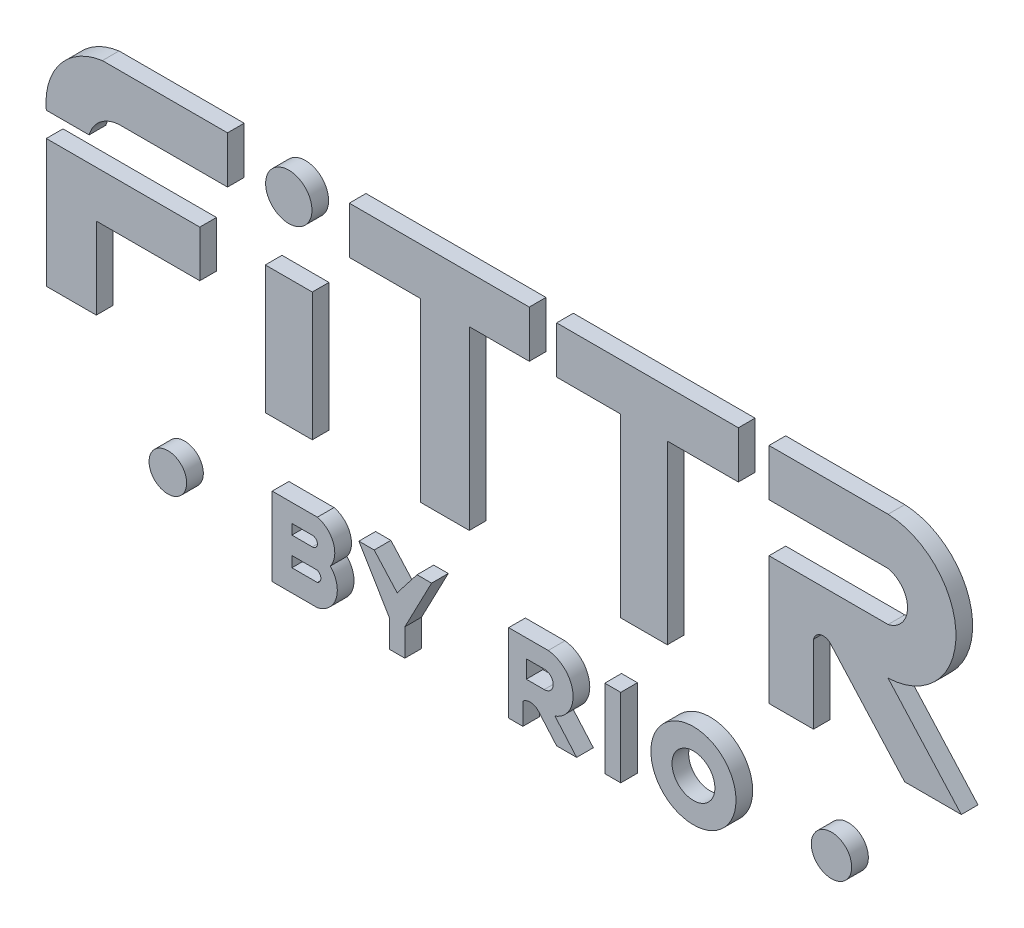
from build123d import *

# Parameters (mm, degrees)
SKETCH1_R              = 13.872950016
BOSS_EXTRUDE1_DEPTH    = 10
SKETCH1_R_2            = 11.261714239
BOSS_EXTRUDE1_2_DEPTH  = 10
SKETCH1_R_3            = 12.095962235
BOSS_EXTRUDE1_3_DEPTH  = 10
SKETCH1_R_4            = 25.497629654
SKETCH1_R_5            = 12.851526445
BOSS_EXTRUDE1_4_DEPTH  = 10
BOSS_EXTRUDE1_5_DEPTH  = 10
SKETCH1_W              = 28.160353525
SKETCH1_H              = 76.692026621
BOSS_EXTRUDE1_6_DEPTH  = 10
BOSS_EXTRUDE1_7_DEPTH  = 10
BOSS_EXTRUDE1_8_DEPTH  = 10
BOSS_EXTRUDE1_9_DEPTH  = 10
BOSS_EXTRUDE1_10_DEPTH = 10
BOSS_EXTRUDE1_11_DEPTH = 10
BOSS_EXTRUDE1_12_DEPTH = 10
BOSS_EXTRUDE1_13_DEPTH = 10
SKETCH1_W_2            = 9.553902
SKETCH1_H_2            = 46.983083585
BOSS_EXTRUDE1_14_DEPTH = 10


with BuildPart() as part:
    # Sketch1 → Boss-Extrude1 (new body)
    with BuildSketch(Plane.XY):
        with Locations((-127.032963832, 2031.122733015)):
            Circle(SKETCH1_R)
    extrude(amount=BOSS_EXTRUDE1_DEPTH)


with BuildPart() as body_2:
    # Sketch1 → Boss-Extrude1 2 (new body)
    with BuildSketch(Plane.XY):
        with Locations((-199.489316183, 1851.962400951)):
            Circle(SKETCH1_R_2)
    extrude(amount=BOSS_EXTRUDE1_2_DEPTH)


with BuildPart() as body_3:
    # Sketch1 → Boss-Extrude1 3 (new body)
    with BuildSketch(Plane.XY):
        with Locations((198.147588845, 1851.962400951)):
            Circle(SKETCH1_R_3)
    extrude(amount=BOSS_EXTRUDE1_3_DEPTH)


with BuildPart() as body_4:
    # Sketch1 → Boss-Extrude1 4 (new body)
    with BuildSketch(Plane.XY):
        with Locations((115.435182788, 1851.962400951)):
            Circle(SKETCH1_R_4)
        with Locations((115.435182788, 1851.962400951)):
            Circle(SKETCH1_R_5, mode=Mode.SUBTRACT)
    extrude(amount=BOSS_EXTRUDE1_4_DEPTH)


with BuildPart() as body_5:
    # Sketch1 → Boss-Extrude1 5 (new body)
    with BuildSketch(Plane.XY):
        Polygon((-272.328404892, 1988.766458193), (-272.328404892, 1912.074431572), (-242.370581993, 1912.074431572), (-242.370581993, 1960.905682897), (-180.357888592, 1960.905682897), (-180.357888592, 1988.766458193), align=None)
    extrude(amount=BOSS_EXTRUDE1_5_DEPTH)


with BuildPart() as body_6:
    # Sketch1 → Boss-Extrude1 6 (new body)
    with BuildSketch(Plane.XY):
        with Locations((-127.032963833, 1950.420444883)):
            Rectangle(SKETCH1_W, SKETCH1_H)
    extrude(amount=BOSS_EXTRUDE1_6_DEPTH)


with BuildPart() as body_7:
    # Sketch1 → Boss-Extrude1 7 (new body)
    with BuildSketch(Plane.XY):
        Polygon((-48.243889609, 2017.825546405), (-48.243889609, 1912.074431572), (-18.885223168, 1912.074431572), (-18.885223168, 2017.825546405), (17.064164311, 2017.825546405), (17.064164311, 2045.98589993), (-90.783998125, 2045.98589993), (-90.783998125, 2017.825546405), align=None)
    extrude(amount=BOSS_EXTRUDE1_7_DEPTH)


with BuildPart() as body_8:
    # Sketch1 → Boss-Extrude1 8 (new body)
    with BuildSketch(Plane.XY):
        Polygon((71.877747221, 2017.825546405), (71.877747221, 1912.074431572), (99.773015751, 1912.074431572), (99.773015751, 2017.825546405), (142.350004559, 2017.825546405), (142.350004559, 2045.98589993), (33.460579157, 2045.98589993), (33.460579157, 2017.825546405), align=None)
    extrude(amount=BOSS_EXTRUDE1_8_DEPTH)


with BuildPart() as body_9:
    # Sketch1 → Boss-Extrude1 9 (new body)
    with BuildSketch(Plane.XY):
        with BuildLine():
            Line((160.702154908, 1988.766458193), (160.702154908, 1912.074431572))
            Line((160.702154908, 1912.074431572), (187.373946748, 1912.074431572))
            Line((187.373946748, 1912.074431572), (187.373946748, 1958.750849803))
            ThreePointArc((187.373946748, 1958.750849803), (192.06601131, 1963.30188004), (198.147588845, 1960.905682897))
            Line((198.147588845, 1960.905682897), (242.016569038, 1912.074431572))
            Line((242.016569038, 1912.074431572), (275.941913721, 1912.074431572))
            Line((275.941913721, 1912.074431572), (232.072933528, 1960.905682897))
            ThreePointArc((232.072933528, 1960.905682897), (272.730878669, 2003.445791413), (232.072933528, 2045.98589993))
            Line((232.072933528, 2045.98589993), (160.702154908, 2045.98589993))
            Line((160.702154908, 2045.98589993), (160.702154908, 2017.825546405))
            Line((160.702154908, 2017.825546405), (232.072933528, 2017.825546405))
            ThreePointArc((232.072933528, 2017.825546405), (243.71530311, 2003.296002299), (232.072933528, 1988.766458193))
            Line((232.072933528, 1988.766458193), (160.702154908, 1988.766458193))
        make_face()
    extrude(amount=BOSS_EXTRUDE1_9_DEPTH)


with BuildPart() as body_10:
    # Sketch1 → Boss-Extrude1 10 (new body)
    with BuildSketch(Plane.XY):
        with BuildLine():
            Line((-272.328404892, 2003.429645733), (-246.670286028, 2003.429645733))
            ThreePointArc((-246.670286028, 2003.429645733), (-239.268889638, 2014.02773476), (-226.91264481, 2017.825546405))
            Line((-226.91264481, 2017.825546405), (-163.75297206, 2017.825546405))
            Line((-163.75297206, 2017.825546405), (-163.75297206, 2045.98589993))
            Line((-163.75297206, 2045.98589993), (-226.912644809, 2045.98589993))
            Line((-226.912644809, 2045.98589993), (-238.734839965, 2045.98589993))
            ThreePointArc((-238.734839965, 2045.98589993), (-264.103032071, 2031.473974692), (-272.328404892, 2003.429645733))
        make_face()
    extrude(amount=BOSS_EXTRUDE1_10_DEPTH)


with BuildPart() as body_11:
    # Sketch1 → Boss-Extrude1 11 (new body)
    with BuildSketch(Plane.XY):
        with BuildLine():
            Line((-136.977925312, 1873.463134117), (-136.977925312, 1826.480050532))
            Line((-136.977925312, 1826.480050532), (-109.902927992, 1826.480050532))
            ThreePointArc((-109.902927992, 1826.480050532), (-98.612469798, 1836.965351507), (-102.148638735, 1851.962400951))
            ThreePointArc((-102.148638735, 1851.962400951), (-100.276299584, 1864.786332187), (-109.902927992, 1873.463134117))
            Line((-109.902927992, 1873.463134117), (-136.977925312, 1873.463134117))
        make_face()
        with BuildLine():
            Line((-125.175267733, 1862.598979878), (-125.175267733, 1856.531151967))
            Line((-125.175267733, 1856.531151967), (-112.95278707, 1856.531151967))
            ThreePointArc((-112.95278707, 1856.531151967), (-109.850175983, 1859.565065922), (-112.95278707, 1862.598979878))
            Line((-112.95278707, 1862.598979878), (-125.175267733, 1862.598979878))
        make_face(mode=Mode.SUBTRACT)
        with BuildLine():
            Line((-125.175267733, 1845.951349454), (-125.175267733, 1839.57235088))
            Line((-125.175267733, 1839.57235088), (-112.95278707, 1839.57235088))
            Line((-112.95278707, 1839.57235088), (-109.902927992, 1839.57235088))
            ThreePointArc((-109.902927992, 1839.57235088), (-107.808637054, 1842.761850167), (-109.902927992, 1845.951349454))
            Line((-109.902927992, 1845.951349454), (-112.95278707, 1845.951349454))
            Line((-112.95278707, 1845.951349454), (-125.175267733, 1845.951349454))
        make_face(mode=Mode.SUBTRACT)
    extrude(amount=BOSS_EXTRUDE1_11_DEPTH)


with BuildPart() as body_12:
    # Sketch1 → Boss-Extrude1 12 (new body)
    with BuildSketch(Plane.XY):
        Polygon((-85.034252317, 1873.463134117), (-66.675183251, 1842.761850167), (-66.675183251, 1826.480050532), (-57.495648718, 1826.480050532), (-57.495648718, 1842.761850167), (-41.470359618, 1873.463134117), (-50.184330229, 1873.463134117), (-62.085415985, 1858.112492142), (-75.854717784, 1873.463134117), align=None)
    extrude(amount=BOSS_EXTRUDE1_12_DEPTH)


with BuildPart() as body_13:
    # Sketch1 → Boss-Extrude1 13 (new body)
    with BuildSketch(Plane.XY):
        with BuildLine():
            Line((4.708619391, 1873.463134117), (4.708619391, 1826.480050532))
            Line((4.708619391, 1826.480050532), (13.228360596, 1826.480050532))
            Line((13.228360596, 1826.480050532), (13.228360596, 1839.57235088))
            ThreePointArc((13.228360596, 1839.57235088), (17.6621462, 1841.265735094), (22.095931804, 1839.57235088))
            Line((22.095931804, 1839.57235088), (33.460579157, 1826.480050532))
            Line((33.460579157, 1826.480050532), (45.440627673, 1826.480050532))
            Line((45.440627673, 1826.480050532), (32.467727531, 1841.425090159))
            ThreePointArc((32.467727531, 1841.425090159), (43.188436735, 1859.056248569), (28.415725354, 1873.463134117))
            Line((28.415725354, 1873.463134117), (4.708619391, 1873.463134117))
        make_face()
        with BuildLine():
            Line((15.265690015, 1862.598979878), (15.265690015, 1851.962400951))
            Line((15.265690015, 1851.962400951), (26.007972405, 1851.962400951))
            ThreePointArc((26.007972405, 1851.962400951), (31.399297294, 1857.280690415), (26.007972405, 1862.598979878))
            Line((26.007972405, 1862.598979878), (15.265690015, 1862.598979878))
        make_face(mode=Mode.SUBTRACT)
    extrude(amount=BOSS_EXTRUDE1_13_DEPTH)


with BuildPart() as body_14:
    # Sketch1 → Boss-Extrude1 14 (new body)
    with BuildSketch(Plane.XY):
        with Locations((67.100796221, 1849.971592325)):
            Rectangle(SKETCH1_W_2, SKETCH1_H_2)
    extrude(amount=BOSS_EXTRUDE1_14_DEPTH)


solid = Compound([part.part, body_2.part, body_3.part, body_4.part, body_5.part, body_6.part, body_7.part, body_8.part, body_9.part, body_10.part, body_11.part, body_12.part, body_13.part, body_14.part])
